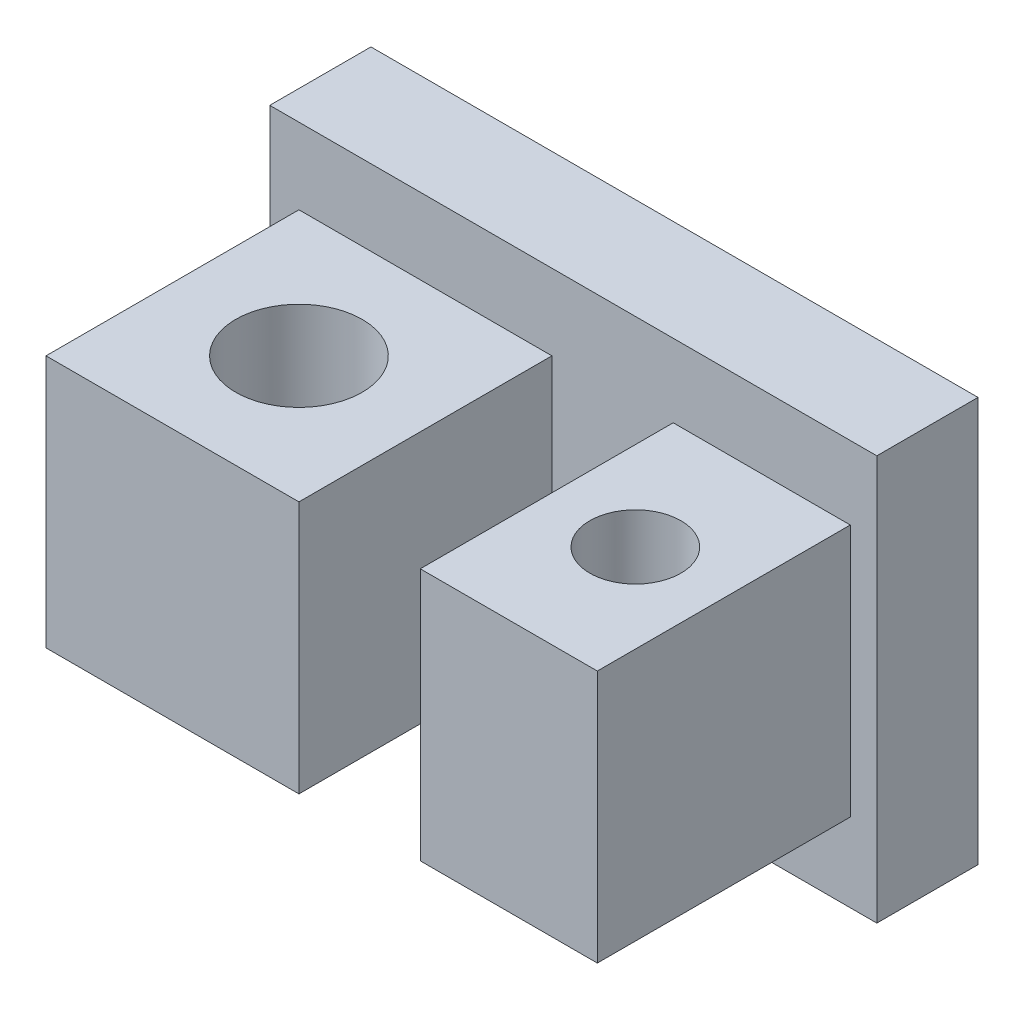
from build123d import *

# Parameters (mm, degrees)
SKETCH_1_W               = 12
SKETCH_1_H               = 8
EXTRUDE_1_DEPTH          = 2
SKETCH_3_W               = 5
SKETCH_3_H               = 5
EXTRUDE_2_DEPTH          = 7
SKETCH_5_R               = 1.25
CUT_EXTRUDE_2_DEPTH      = 5
CUT_EXTRUDE_2_DEPTH_BACK = 5
SKETCH_6_W               = 3.5
SKETCH_6_H               = 5
EXTRUDE_3_DEPTH          = 7
SKETCH_8_R               = 0.9
CUT_EXTRUDE_3_DEPTH      = 7
CUT_EXTRUDE_3_DEPTH_BACK = 7


with BuildPart() as part:
    # 草圖1 → 填料-伸長1 (new body)
    with BuildSketch(Plane.XY):
        with Locations((1.458189105, 0.025974026)):
            Rectangle(SKETCH_1_W, SKETCH_1_H)
    extrude(amount=EXTRUDE_1_DEPTH)

    # 草圖3 → 填料-伸長2 (add)
    with BuildSketch(Plane.XY):
        with Locations((-1.465017587, 0.025974026)):
            Rectangle(SKETCH_3_W, SKETCH_3_H)
    extrude(amount=EXTRUDE_2_DEPTH)

    # 草圖5 → 除料-伸長2 (cut, two sides)
    with BuildSketch(Plane(origin=(0, 0, 0), x_dir=(1, 0, 0), z_dir=(0, 1, 0))) as cut_extrude_2_sk:
        with Locations((-1.465017587, -4.5)):
            Circle(SKETCH_5_R)
    extrude(amount=CUT_EXTRUDE_2_DEPTH, mode=Mode.SUBTRACT)
    extrude(cut_extrude_2_sk.sketch, amount=-CUT_EXTRUDE_2_DEPTH_BACK, mode=Mode.SUBTRACT)

    # 草圖6 → 填料-伸長3 (add)
    with BuildSketch(Plane.XY):
        with Locations((5.183136142, 0.079162411)):
            Rectangle(SKETCH_6_W, SKETCH_6_H)
    extrude(amount=EXTRUDE_3_DEPTH)

    # 草圖8 → 除料-伸長3 (cut, two sides)
    with BuildSketch(Plane(origin=(0, 0, 0), x_dir=(1, 0, 0), z_dir=(0, 1, 0))) as cut_extrude_3_sk:
        with Locations((5.184982413, -4.5)):
            Circle(SKETCH_8_R)
    extrude(amount=CUT_EXTRUDE_3_DEPTH, mode=Mode.SUBTRACT)
    extrude(cut_extrude_3_sk.sketch, amount=-CUT_EXTRUDE_3_DEPTH_BACK, mode=Mode.SUBTRACT)


solid = part.part
